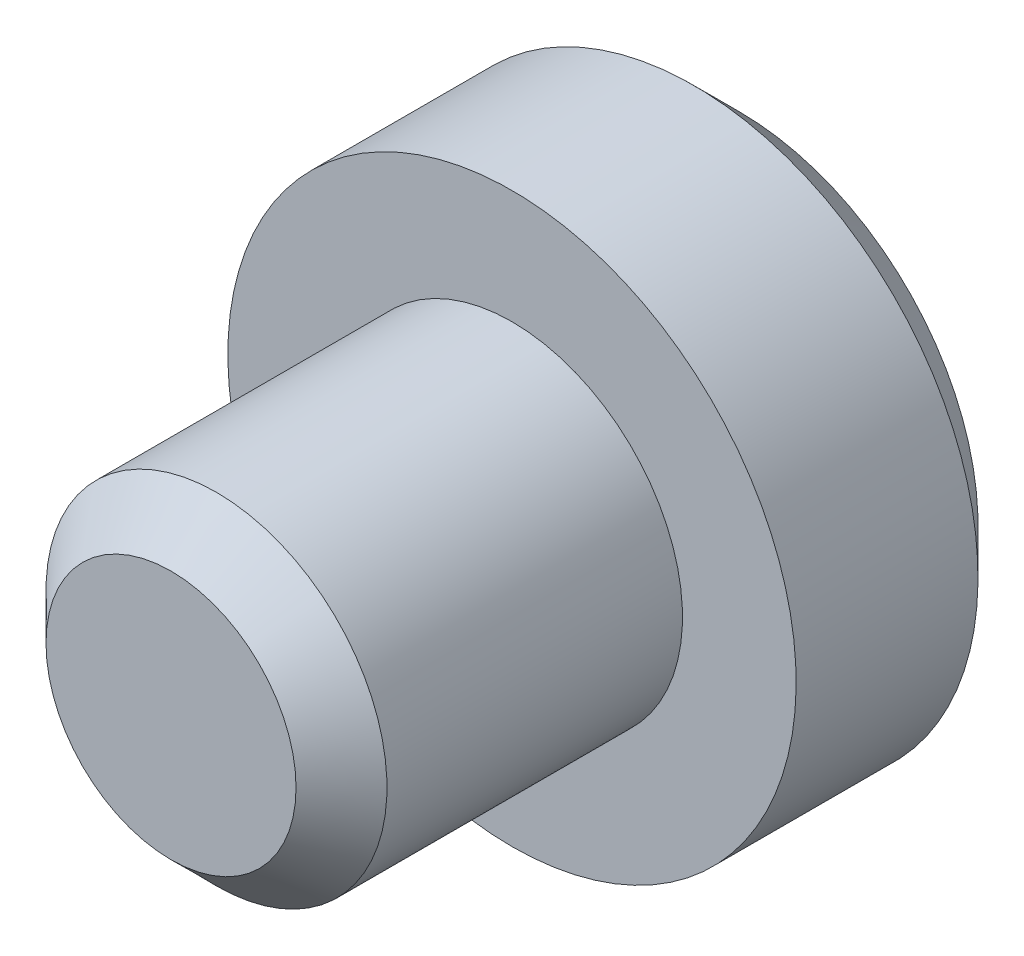
from build123d import *

# Parameters (mm, degrees)
CUT_EXTRUDE1_DEPTH = 2
CHAMFER1_SIZE      = 0.4
CHAMFER2_SIZE      = 0.1


with BuildPart() as part:
    # Sketch2 → Revolve1 (revolve)
    with BuildSketch(Plane(origin=(0, 0, 0), x_dir=(0, 0, -1), z_dir=(1, 0, 0))):
        Polygon((0, 2.5), (-2, 2.5), (-2, 1.5), (-5, 1.5), (-5, 0), (0, 0), align=None)
    revolve(axis=Axis((0, 0, 5), (0, 0, -1)))

    # Sketch3 → Cut-Extrude1 (cut)
    with BuildSketch(Plane(origin=(0, 0, 0), x_dir=(-1, 0, 0), z_dir=(0, 0, -1))):
        Polygon((1.168445951, -0.498063644), (1.015558744, 0.762872054), (-0.152887207, 1.260935698), (-1.168445951, 0.498063644), (-1.015558744, -0.762872054), (0.152887207, -1.260935698), align=None)
    extrude(amount=-CUT_EXTRUDE1_DEPTH, mode=Mode.SUBTRACT)

    # Chamfer1
    chamfer1_edges = [part.edges().sort_by_distance(p)[0] for p in [
        (0, -1.5, 5),
        (0, -2.5, 0),
    ]]
    chamfer(chamfer1_edges, length=CHAMFER1_SIZE)

    # Chamfer2
    chamfer2_edges = [part.edges().sort_by_distance(p)[0] for p in [
        (-0.660666579, -0.879499671, 0),
        (-1.092002347, 0.132404205, 0),
        (-0.431335769, 1.011903876, 0),
        (0.660666579, 0.879499671, 0),
        (1.092002347, -0.132404205, 0),
        (0.431335769, -1.011903876, 0),
    ]]
    chamfer(chamfer2_edges, length=CHAMFER2_SIZE)


solid = part.part
